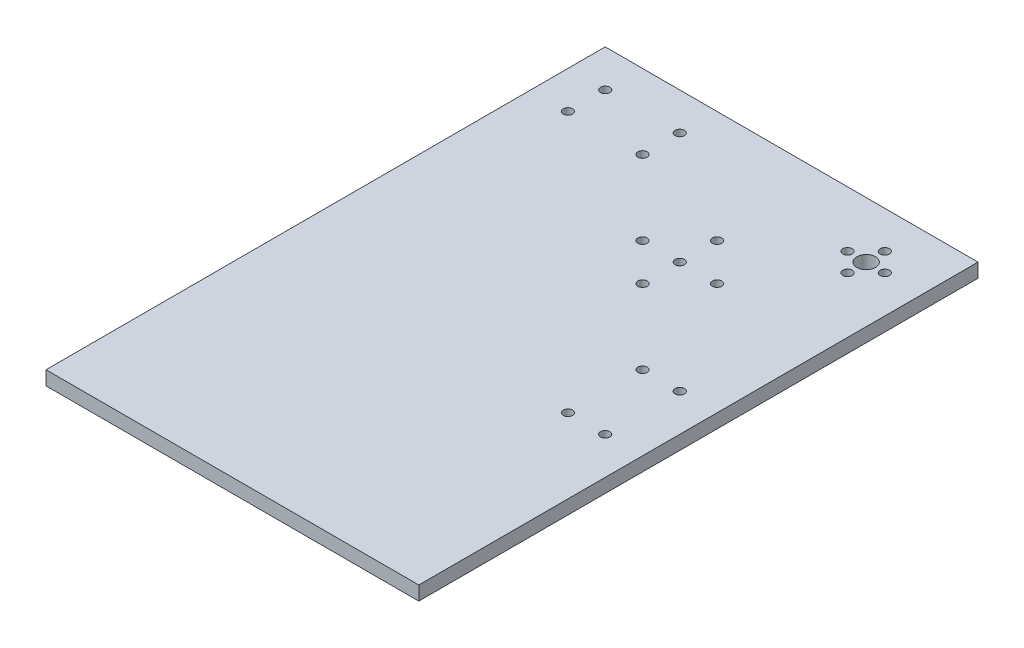
from build123d import *

# Parameters (mm, degrees)
SKETCH1_W                   = 254
SKETCH1_H                   = 254
BOSS_EXTRUDE1_DEPTH         = 9.525
F_1_4_0_25_DIAMETER_HOLE1_D = 6.35
F_1_2_0_5_DIAMETER_HOLE1_D  = 12.7
SKETCH8_W                   = 254
SKETCH8_H                   = 9.525
BOSS_EXTRUDE2_DEPTH         = 127


with BuildPart() as part:
    # Sketch1 → Boss-Extrude1 (new body)
    with BuildSketch(Plane(origin=(0, 0, 0), x_dir=(1, 0, 0), z_dir=(0, 1, 0))):
        Rectangle(SKETCH1_W, SKETCH1_H)
    extrude(amount=BOSS_EXTRUDE1_DEPTH)

    # 1/4 (0.25) Diameter Hole1 (through all)
    with Locations(Plane(origin=(0, 9.525, 0), x_dir=(1, 0, 0), z_dir=(0, 1, 0))):
        with Locations((-50.8, 76.2), (-50.8, 101.6), (76.2, -50.8), (101.6, -50.8), (76.2, -101.6), (101.6, -101.6), (-101.6, 76.2), (-101.6, 101.6), (25.4, 50.8), (50.8, 25.4), (25.4, 0), (0, 25.4), (25.4, 25.4), (88.9, 76.2), (76.2, 88.9), (88.9, 101.6), (101.6, 88.9)):
            Hole(F_1_4_0_25_DIAMETER_HOLE1_D / 2)

    # 1/2 (0.5) Diameter Hole1 (through all)
    with Locations(Plane(origin=(0, 9.525, 0), x_dir=(1, 0, 0), z_dir=(0, 1, 0))):
        with Locations((88.9, 88.9)):
            Hole(F_1_2_0_5_DIAMETER_HOLE1_D / 2)

    # Sketch8 → Boss-Extrude2 (add)
    with BuildSketch(Plane.XY.offset(127)):
        with Locations((0, 4.7625)):
            Rectangle(SKETCH8_W, SKETCH8_H)
    extrude(amount=BOSS_EXTRUDE2_DEPTH)


solid = part.part
